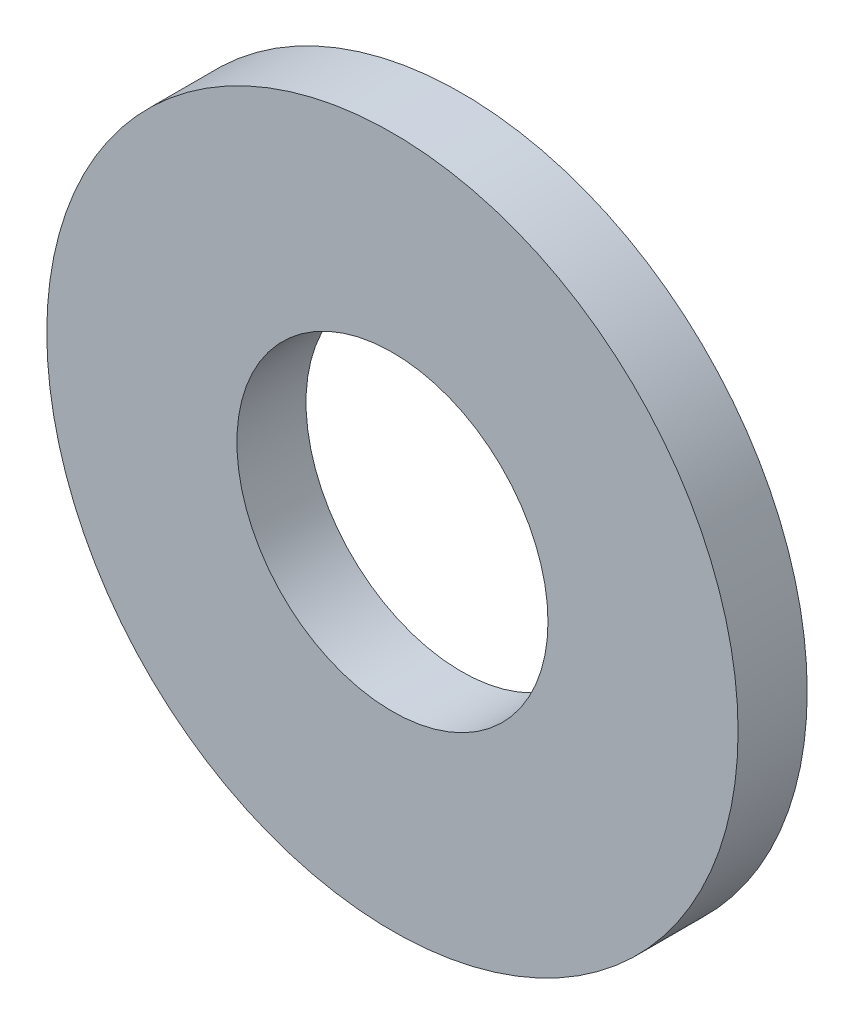
from build123d import *

# Parameters (mm, degrees)
SKETCH1_R           = 7.9375
SKETCH1_R_2         = 3.571875
BOSS_EXTRUDE1_DEPTH = 1.5875


with BuildPart() as part:
    # Sketch1 → Boss-Extrude1 (new body)
    with BuildSketch(Plane.XY):
        Circle(SKETCH1_R)
        Circle(SKETCH1_R_2, mode=Mode.SUBTRACT)
    extrude(amount=BOSS_EXTRUDE1_DEPTH)


solid = part.part
